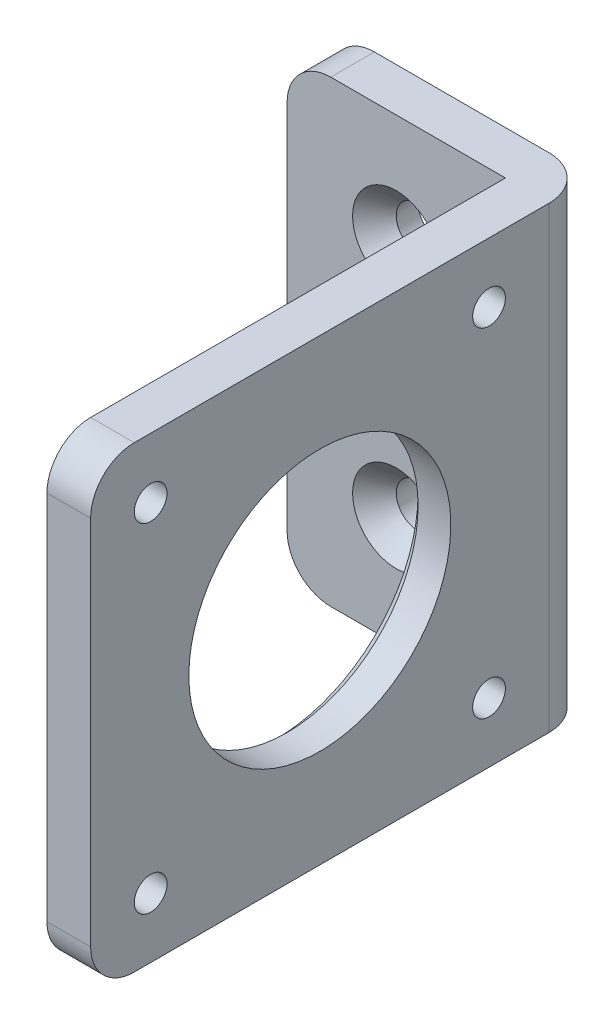
from build123d import *

# Parameters (mm, degrees)
BOSS_EXTRUDE1_DEPTH = 42
SKETCH2_R           = 12
SKETCH2_R_2         = 1.5
CUT_EXTRUDE1_DEPTH  = 5
SKETCH3_R           = 2
CUT_EXTRUDE2_DEPTH  = 5
CHAMFER1_SIZE       = 2
CHAMFER2_SIZE       = 1
FILLET1_R           = 4


with BuildPart() as part:
    # Sketch1 → Boss-Extrude1 (new body)
    with BuildSketch(Plane(origin=(0, 0, 0), x_dir=(1, 0, 0), z_dir=(0, 1, 0))):
        Polygon((0, 0), (0, 42), (-20, 42), (-20, 46), (4, 46), (4, 0), align=None)
    extrude(amount=BOSS_EXTRUDE1_DEPTH)

    # Sketch2 → Cut-Extrude1 (cut, through all)
    with BuildSketch(Plane.ZY):
        with Locations((-21, 21)):
            Circle(SKETCH2_R)
        with Locations((-36.5, 36.5)):
            Circle(SKETCH2_R_2)
        with Locations((-5.5, 36.5)):
            Circle(SKETCH2_R_2)
        with Locations((-5.5, 5.5)):
            Circle(SKETCH2_R_2)
        with Locations((-36.5, 5.5)):
            Circle(SKETCH2_R_2)
    extrude(amount=-CUT_EXTRUDE1_DEPTH, mode=Mode.SUBTRACT)

    # Sketch3 → Cut-Extrude2 (cut, through all)
    with BuildSketch(Plane.XY.offset(-42)):
        with Locations((-10, 32)):
            Circle(SKETCH3_R)
        with Locations((-10, 10)):
            Circle(SKETCH3_R)
    extrude(amount=-CUT_EXTRUDE2_DEPTH, mode=Mode.SUBTRACT)

    # Chamfer1
    chamfer1_edges = [part.edges().sort_by_distance(p)[0] for p in [
        (-12, 32, -42),
        (-12, 10, -42),
    ]]
    chamfer(chamfer1_edges, length=CHAMFER1_SIZE)

    # Chamfer2
    chamfer2_edges = [part.edges().sort_by_distance(p)[0] for p in [
        (0, 21, -33),
    ]]
    chamfer(chamfer2_edges, length=CHAMFER2_SIZE)

    # Fillet1
    fillet1_edges = [part.edges().sort_by_distance(p)[0] for p in [
        (4, 21, -46),
        (-20, 42, -44),
        (2, 42, 0),
        (-20, 0, -44),
        (2, 0, 0),
    ]]
    fillet(fillet1_edges, radius=FILLET1_R)


solid = part.part
